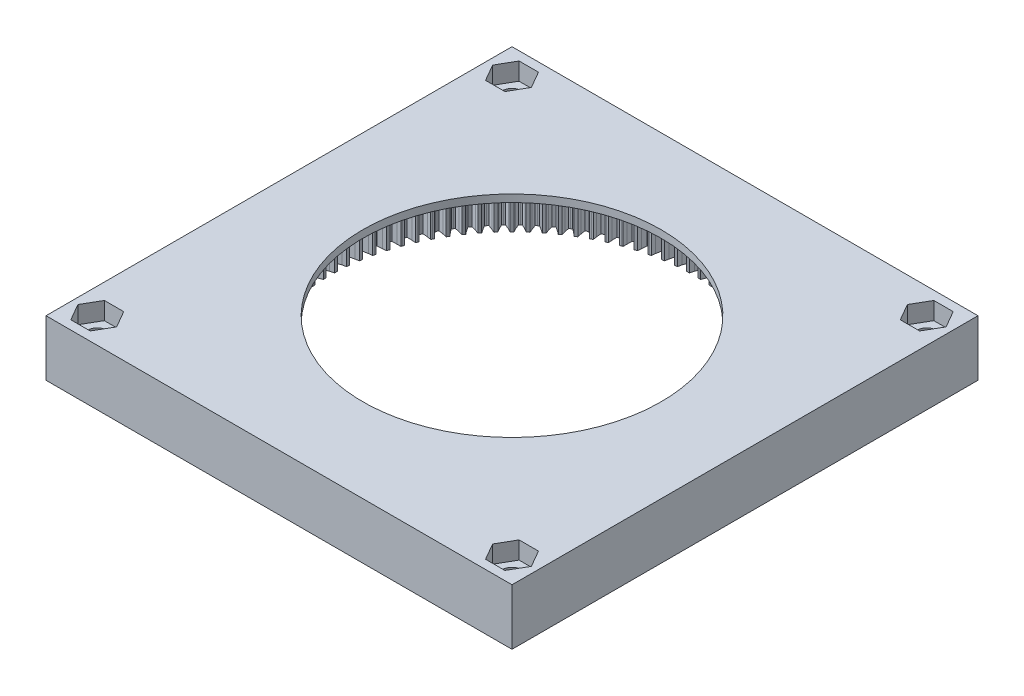
from build123d import *

# Parameters (mm, degrees)
SKETCH1_W           = 158.75
SKETCH1_H           = 158.75
BOSS_EXTRUDE1_DEPTH = 19.05
SKETCH7_R           = 3.37312
CUT_EXTRUDE2_DEPTH  = 19.05
SKETCH8_R           = 50.8
CUT_EXTRUDE3_DEPTH  = 19.05
CUT_EXTRUDE5_DEPTH  = 16.51
CUT_EXTRUDE6_DEPTH  = 5.969


with BuildPart() as part:
    # Sketch1 → Boss-Extrude1 (new body)
    with BuildSketch(Plane(origin=(0, 0, 0), x_dir=(1, 0, 0), z_dir=(0, 1, 0))):
        Rectangle(SKETCH1_W, SKETCH1_H)
    extrude(amount=BOSS_EXTRUDE1_DEPTH)

    # Sketch7 → Cut-Extrude2 (cut)
    with BuildSketch(Plane(origin=(0, 0, 0), x_dir=(1, 0, 0), z_dir=(0, 1, 0))):
        with Locations((-70.64375, 70.64375)):
            Circle(SKETCH7_R)
        with Locations((70.64375, 70.64375)):
            Circle(SKETCH7_R)
        with Locations((70.64375, -70.64375)):
            Circle(SKETCH7_R)
        with Locations((-70.64375, -70.64375)):
            Circle(SKETCH7_R)
    extrude(amount=CUT_EXTRUDE2_DEPTH, mode=Mode.SUBTRACT)

    # Sketch8 → Cut-Extrude3 (cut)
    with BuildSketch(Plane(origin=(0, 0, 0), x_dir=(1, 0, 0), z_dir=(0, 1, 0))):
        Circle(SKETCH8_R)
    extrude(amount=CUT_EXTRUDE3_DEPTH, mode=Mode.SUBTRACT)

    # Sketch10 → Cut-Extrude5 (cut)
    with BuildSketch(Plane.XZ):
        Polygon((61.894879047, -1.477025374), (63.199005913, -1.096565737), (64.767971828, -0.512567385), (64.77, 0), (64.767971828, 0.512567385), (63.199005913, 1.096565737), (61.894879047, 1.477025374), (61.881949919, 1.944718621), (61.865486833, 2.41230081), (63.143151044, 2.8738965), (64.672351403, 3.555258649), (64.6421912, 4.06694195), (64.607982658, 4.578370551), (63.005443179, 5.06270033), (61.680000452, 5.360522414), (61.637730133, 5.826480948), (61.591939805, 6.292106744), (62.838099005, 6.83301678), (64.321498752, 7.609053702), (64.259269204, 8.117833538), (64.193015297, 8.626104979), (62.563226745, 9.008854758), (61.221699073, 9.22286392), (61.150254387, 9.685248817), (61.07531753, 10.147080608), (62.285053697, 10.765170265), (63.716798532, 11.632819296), (63.62274523, 12.136687746), (63.524707431, 12.639796112), (61.874101838, 12.919455352), (60.521783617, 13.048806996), (60.421446524, 13.505793433), (60.317658879, 13.96200858), (61.486197737, 14.654838541), (62.860637218, 15.610675467), (62.735131346, 16.107643992), (62.605696568, 16.603603744), (60.940788118, 16.779068758), (59.583016332, 16.823252392), (59.454182814, 17.273036853), (59.321953985, 17.721834884), (60.444683845, 18.486670865), (61.756393687, 19.526923434), (61.59993056, 20.015030726), (61.439609621, 20.501884538), (59.766968949, 20.572462845), (58.409102102, 20.531304097), (58.252280608, 20.972111487), (58.09213244, 21.411721201), (59.164622401, 22.245544744), (60.408425884, 23.366107555), (60.221622991, 23.843427277), (60.031048605, 24.31925376), (58.357276858, 24.28466682), (57.00467383, 24.158328125), (56.820483263, 24.588418779), (56.633047789, 25.017105237), (57.651065222, 25.916625621), (58.822053621, 27.113076324), (58.605648188, 27.577724715), (58.385572465, 28.040645997), (56.717275256, 27.901030309), (55.375274154, 27.690010268), (55.164441429, 28.107686815), (54.95045837, 28.523758187), (55.909985627, 29.485425417), (57.003537587, 30.753042168), (56.758383666, 31.203185472), (56.509675144, 31.651374616), (54.853436481, 31.407281179), (53.527333569, 31.112412591), (53.290690747, 31.516026653), (53.051004598, 31.917840896), (53.948254861, 32.93785971), (54.960054632, 34.271639805), (54.687119735, 34.705501511), (54.410759953, 35.137189719), (52.773116252, 34.789581859), (51.468145053, 34.412028436), (51.206626055, 34.799987131), (50.942182746, 35.185958468), (51.77361498, 36.260303318), (52.69966945, 37.654982936), (52.400030726, 38.070850791), (52.09711035, 38.484334387), (50.484524643, 38.034583952), (49.205835282, 37.575835725), (48.920472204, 37.946607959), (48.632315373, 38.315213137), (49.394648294, 39.439644075), (50.231302749, 40.889719052), (49.906142735, 41.285951816), (49.577857253, 41.679598969), (47.996693679, 41.12948092), (46.749332559, 40.591348358), (46.441251598, 40.943470862), (46.130518469, 41.293255164), (46.820743497, 42.463334575), (47.564696044, 43.963082128), (47.215297998, 44.338116051), (46.862943004, 44.710373215), (45.319441693, 44.062058616), (44.108331578, 43.446665483), (43.77874859, 43.77874859), (43.446665483, 44.108331578), (44.062058616, 45.319441693), (44.710373215, 46.862943004), (44.338116051, 47.215297998), (43.963082128, 47.564696044), (42.463334575, 46.820743497), (41.293255164, 46.130518469), (40.943470862, 46.441251598), (40.591348358, 46.749332559), (41.12948092, 47.996693679), (41.679598969, 49.577857253), (41.285951816, 49.906142735), (40.889719052, 50.231302749), (39.439644075, 49.394648294), (38.315213137, 48.632315373), (37.946607959, 48.920472204), (37.575835725, 49.205835282), (38.034583952, 50.484524643), (38.484334387, 52.09711035), (38.070850791, 52.400030726), (37.654982936, 52.69966945), (36.260303318, 51.77361498), (35.185958468, 50.942182746), (34.799987131, 51.206626055), (34.412028436, 51.468145053), (34.789581859, 52.773116252), (35.137189719, 54.410759953), (34.705501511, 54.687119735), (34.271639805, 54.960054632), (32.93785971, 53.948254861), (31.917840896, 53.051004598), (31.516026653, 53.290690747), (31.112412591, 53.527333569), (31.407281179, 54.853436481), (31.651374616, 56.509675144), (31.203185472, 56.758383666), (30.753042168, 57.003537587), (29.485425417, 55.909985627), (28.523758187, 54.95045837), (28.107686815, 55.164441429), (27.690010268, 55.375274154), (27.901030309, 56.717275256), (28.040645997, 58.385572465), (27.577724715, 58.605648188), (27.113076324, 58.822053621), (25.916625621, 57.651065222), (25.017105237, 56.633047789), (24.588418779, 56.820483263), (24.158328125, 57.00467383), (24.28466682, 58.357276858), (24.31925376, 60.031048605), (23.843427277, 60.221622991), (23.366107555, 60.408425884), (22.245544744, 59.164622401), (21.411721201, 58.09213244), (20.972111487, 58.252280608), (20.531304097, 58.409102102), (20.572462845, 59.766968949), (20.501884538, 61.439609621), (20.015030726, 61.59993056), (19.526923434, 61.756393687), (18.486670865, 60.444683845), (17.721834884, 59.321953985), (17.273036853, 59.454182814), (16.823252392, 59.583016332), (16.779068758, 60.940788118), (16.603603744, 62.605696568), (16.107643992, 62.735131346), (15.610675467, 62.860637218), (14.654838541, 61.486197737), (13.96200858, 60.317658879), (13.505793433, 60.421446524), (13.048806996, 60.521783617), (12.919455352, 61.874101838), (12.639796112, 63.524707431), (12.136687746, 63.62274523), (11.632819296, 63.716798532), (10.765170265, 62.285053697), (10.147080608, 61.07531753), (9.685248817, 61.150254387), (9.22286392, 61.221699073), (9.008854758, 62.563226745), (8.626104979, 64.193015297), (8.117833538, 64.259269204), (7.609053702, 64.321498752), (6.83301678, 62.838099005), (6.292106744, 61.591939805), (5.826480948, 61.637730133), (5.360522414, 61.680000452), (5.06270033, 63.005443179), (4.578370551, 64.607982658), (4.06694195, 64.6421912), (3.555258649, 64.672351403), (2.8738965, 63.143151044), (2.41230081, 61.865486833), (1.944718621, 61.881949919), (1.477025374, 61.894879047), (1.096565737, 63.199005913), (0.512567385, 64.767971828), (0, 64.77), (-0.512567385, 64.767971828), (-1.096565737, 63.199005913), (-1.477025374, 61.894879047), (-1.944718621, 61.881949919), (-2.41230081, 61.865486833), (-2.8738965, 63.143151044), (-3.555258649, 64.672351403), (-4.06694195, 64.6421912), (-4.578370551, 64.607982658), (-5.06270033, 63.005443179), (-5.360522414, 61.680000452), (-5.826480948, 61.637730133), (-6.292106744, 61.591939805), (-6.83301678, 62.838099005), (-7.609053702, 64.321498752), (-8.117833538, 64.259269204), (-8.626104979, 64.193015297), (-9.008854758, 62.563226745), (-9.22286392, 61.221699073), (-9.685248817, 61.150254387), (-10.147080608, 61.07531753), (-10.765170265, 62.285053697), (-11.632819296, 63.716798532), (-12.136687746, 63.62274523), (-12.639796112, 63.524707431), (-12.919455352, 61.874101838), (-13.048806996, 60.521783617), (-13.505793433, 60.421446524), (-13.96200858, 60.317658879), (-14.654838541, 61.486197737), (-15.610675467, 62.860637218), (-16.107643992, 62.735131346), (-16.603603744, 62.605696568), (-16.779068758, 60.940788118), (-16.823252392, 59.583016332), (-17.273036853, 59.454182814), (-17.721834884, 59.321953985), (-18.486670865, 60.444683845), (-19.526923434, 61.756393687), (-20.015030726, 61.59993056), (-20.501884538, 61.439609621), (-20.572462845, 59.766968949), (-20.531304097, 58.409102102), (-20.972111487, 58.252280608), (-21.411721201, 58.09213244), (-22.245544744, 59.164622401), (-23.366107555, 60.408425884), (-23.843427277, 60.221622991), (-24.31925376, 60.031048605), (-24.28466682, 58.357276858), (-24.158328125, 57.00467383), (-24.588418779, 56.820483263), (-25.017105237, 56.633047789), (-25.916625621, 57.651065222), (-27.113076324, 58.822053621), (-27.577724715, 58.605648188), (-28.040645997, 58.385572465), (-27.901030309, 56.717275256), (-27.690010268, 55.375274154), (-28.107686815, 55.164441429), (-28.523758187, 54.95045837), (-29.485425417, 55.909985627), (-30.753042168, 57.003537587), (-31.203185472, 56.758383666), (-31.651374616, 56.509675144), (-31.407281179, 54.853436481), (-31.112412591, 53.527333569), (-31.516026653, 53.290690747), (-31.917840896, 53.051004598), (-32.93785971, 53.948254861), (-34.271639805, 54.960054632), (-34.705501511, 54.687119735), (-35.137189719, 54.410759953), (-34.789581859, 52.773116252), (-34.412028436, 51.468145053), (-34.799987131, 51.206626055), (-35.185958468, 50.942182746), (-36.260303318, 51.77361498), (-37.654982936, 52.69966945), (-38.070850791, 52.400030726), (-38.484334387, 52.09711035), (-38.034583952, 50.484524643), (-37.575835725, 49.205835282), (-37.946607959, 48.920472204), (-38.315213137, 48.632315373), (-39.439644075, 49.394648294), (-40.889719052, 50.231302749), (-41.285951816, 49.906142735), (-41.679598969, 49.577857253), (-41.12948092, 47.996693679), (-40.591348358, 46.749332559), (-40.943470862, 46.441251598), (-41.293255164, 46.130518469), (-42.463334575, 46.820743497), (-43.963082128, 47.564696044), (-44.338116051, 47.215297998), (-44.710373215, 46.862943004), (-44.062058616, 45.319441693), (-43.446665483, 44.108331578), (-43.77874859, 43.77874859), (-44.108331578, 43.446665483), (-45.319441693, 44.062058616), (-46.862943004, 44.710373215), (-47.215297998, 44.338116051), (-47.564696044, 43.963082128), (-46.820743497, 42.463334575), (-46.130518469, 41.293255164), (-46.441251598, 40.943470862), (-46.749332559, 40.591348358), (-47.996693679, 41.12948092), (-49.577857253, 41.679598969), (-49.906142735, 41.285951816), (-50.231302749, 40.889719052), (-49.394648294, 39.439644075), (-48.632315373, 38.315213137), (-48.920472204, 37.946607959), (-49.205835282, 37.575835725), (-50.484524643, 38.034583952), (-52.09711035, 38.484334387), (-52.400030726, 38.070850791), (-52.69966945, 37.654982936), (-51.77361498, 36.260303318), (-50.942182746, 35.185958468), (-51.206626055, 34.799987131), (-51.468145053, 34.412028436), (-52.773116252, 34.789581859), (-54.410759953, 35.137189719), (-54.687119735, 34.705501511), (-54.960054632, 34.271639805), (-53.948254861, 32.93785971), (-53.051004598, 31.917840896), (-53.290690747, 31.516026653), (-53.527333569, 31.112412591), (-54.853436481, 31.407281179), (-56.509675144, 31.651374616), (-56.758383666, 31.203185472), (-57.003537587, 30.753042168), (-55.909985627, 29.485425417), (-54.95045837, 28.523758187), (-55.164441429, 28.107686815), (-55.375274154, 27.690010268), (-56.717275256, 27.901030309), (-58.385572465, 28.040645997), (-58.605648188, 27.577724715), (-58.822053621, 27.113076324), (-57.651065222, 25.916625621), (-56.633047789, 25.017105237), (-56.820483263, 24.588418779), (-57.00467383, 24.158328125), (-58.357276858, 24.28466682), (-60.031048605, 24.31925376), (-60.221622991, 23.843427277), (-60.408425884, 23.366107555), (-59.164622401, 22.245544744), (-58.09213244, 21.411721201), (-58.252280608, 20.972111487), (-58.409102102, 20.531304097), (-59.766968949, 20.572462845), (-61.439609621, 20.501884538), (-61.59993056, 20.015030726), (-61.756393687, 19.526923434), (-60.444683845, 18.486670865), (-59.321953985, 17.721834884), (-59.454182814, 17.273036853), (-59.583016332, 16.823252392), (-60.940788118, 16.779068758), (-62.605696568, 16.603603744), (-62.735131346, 16.107643992), (-62.860637218, 15.610675467), (-61.486197737, 14.654838541), (-60.317658879, 13.96200858), (-60.421446524, 13.505793433), (-60.521783617, 13.048806996), (-61.874101838, 12.919455352), (-63.524707431, 12.639796112), (-63.62274523, 12.136687746), (-63.716798532, 11.632819296), (-62.285053697, 10.765170265), (-61.07531753, 10.147080608), (-61.150254387, 9.685248817), (-61.221699073, 9.22286392), (-62.563226745, 9.008854758), (-64.193015297, 8.626104979), (-64.259269204, 8.117833538), (-64.321498752, 7.609053702), (-62.838099005, 6.83301678), (-61.591939805, 6.292106744), (-61.637730133, 5.826480948), (-61.680000452, 5.360522414), (-63.005443179, 5.06270033), (-64.607982658, 4.578370551), (-64.6421912, 4.06694195), (-64.672351403, 3.555258649), (-63.143151044, 2.8738965), (-61.865486833, 2.41230081), (-61.881949919, 1.944718621), (-61.894879047, 1.477025374), (-63.199005913, 1.096565737), (-64.767971828, 0.512567385), (-64.77, 0), (-64.767971828, -0.512567385), (-63.199005913, -1.096565737), (-61.894879047, -1.477025374), (-61.881949919, -1.944718621), (-61.865486833, -2.41230081), (-63.143151044, -2.8738965), (-64.672351403, -3.555258649), (-64.6421912, -4.06694195), (-64.607982658, -4.578370551), (-63.005443179, -5.06270033), (-61.680000452, -5.360522414), (-61.637730133, -5.826480948), (-61.591939805, -6.292106744), (-62.838099005, -6.83301678), (-64.321498752, -7.609053702), (-64.259269204, -8.117833538), (-64.193015297, -8.626104979), (-62.563226745, -9.008854758), (-61.221699073, -9.22286392), (-61.150254387, -9.685248817), (-61.07531753, -10.147080608), (-62.285053697, -10.765170265), (-63.716798532, -11.632819296), (-63.62274523, -12.136687746), (-63.524707431, -12.639796112), (-61.874101838, -12.919455352), (-60.521783617, -13.048806996), (-60.421446524, -13.505793433), (-60.317658879, -13.96200858), (-61.486197737, -14.654838541), (-62.860637218, -15.610675467), (-62.735131346, -16.107643992), (-62.605696568, -16.603603744), (-60.940788118, -16.779068758), (-59.583016332, -16.823252392), (-59.454182814, -17.273036853), (-59.321953985, -17.721834884), (-60.444683845, -18.486670865), (-61.756393687, -19.526923434), (-61.59993056, -20.015030726), (-61.439609621, -20.501884538), (-59.766968949, -20.572462845), (-58.409102102, -20.531304097), (-58.252280608, -20.972111487), (-58.09213244, -21.411721201), (-59.164622401, -22.245544744), (-60.408425884, -23.366107555), (-60.221622991, -23.843427277), (-60.031048605, -24.31925376), (-58.357276858, -24.28466682), (-57.00467383, -24.158328125), (-56.820483263, -24.588418779), (-56.633047789, -25.017105237), (-57.651065222, -25.916625621), (-58.822053621, -27.113076324), (-58.605648188, -27.577724715), (-58.385572465, -28.040645997), (-56.717275256, -27.901030309), (-55.375274154, -27.690010268), (-55.164441429, -28.107686815), (-54.95045837, -28.523758187), (-55.909985627, -29.485425417), (-57.003537587, -30.753042168), (-56.758383666, -31.203185472), (-56.509675144, -31.651374616), (-54.853436481, -31.407281179), (-53.527333569, -31.112412591), (-53.290690747, -31.516026653), (-53.051004598, -31.917840896), (-53.948254861, -32.93785971), (-54.960054632, -34.271639805), (-54.687119735, -34.705501511), (-54.410759953, -35.137189719), (-52.773116252, -34.789581859), (-51.468145053, -34.412028436), (-51.206626055, -34.799987131), (-50.942182746, -35.185958468), (-51.77361498, -36.260303318), (-52.69966945, -37.654982936), (-52.400030726, -38.070850791), (-52.09711035, -38.484334387), (-50.484524643, -38.034583952), (-49.205835282, -37.575835725), (-48.920472204, -37.946607959), (-48.632315373, -38.315213137), (-49.394648294, -39.439644075), (-50.231302749, -40.889719052), (-49.906142735, -41.285951816), (-49.577857253, -41.679598969), (-47.996693679, -41.12948092), (-46.749332559, -40.591348358), (-46.441251598, -40.943470862), (-46.130518469, -41.293255164), (-46.820743497, -42.463334575), (-47.564696044, -43.963082128), (-47.215297998, -44.338116051), (-46.862943004, -44.710373215), (-45.319441693, -44.062058616), (-44.108331578, -43.446665483), (-43.77874859, -43.77874859), (-43.446665483, -44.108331578), (-44.062058616, -45.319441693), (-44.710373215, -46.862943004), (-44.338116051, -47.215297998), (-43.963082128, -47.564696044), (-42.463334575, -46.820743497), (-41.293255164, -46.130518469), (-40.943470862, -46.441251598), (-40.591348358, -46.749332559), (-41.12948092, -47.996693679), (-41.679598969, -49.577857253), (-41.285951816, -49.906142735), (-40.889719052, -50.231302749), (-39.439644075, -49.394648294), (-38.315213137, -48.632315373), (-37.946607959, -48.920472204), (-37.575835725, -49.205835282), (-38.034583952, -50.484524643), (-38.484334387, -52.09711035), (-38.070850791, -52.400030726), (-37.654982936, -52.69966945), (-36.260303318, -51.77361498), (-35.185958468, -50.942182746), (-34.799987131, -51.206626055), (-34.412028436, -51.468145053), (-34.789581859, -52.773116252), (-35.137189719, -54.410759953), (-34.705501511, -54.687119735), (-34.271639805, -54.960054632), (-32.93785971, -53.948254861), (-31.917840896, -53.051004598), (-31.516026653, -53.290690747), (-31.112412591, -53.527333569), (-31.407281179, -54.853436481), (-31.651374616, -56.509675144), (-31.203185472, -56.758383666), (-30.753042168, -57.003537587), (-29.485425417, -55.909985627), (-28.523758187, -54.95045837), (-28.107686815, -55.164441429), (-27.690010268, -55.375274154), (-27.901030309, -56.717275256), (-28.040645997, -58.385572465), (-27.577724715, -58.605648188), (-27.113076324, -58.822053621), (-25.916625621, -57.651065222), (-25.017105237, -56.633047789), (-24.588418779, -56.820483263), (-24.158328125, -57.00467383), (-24.28466682, -58.357276858), (-24.31925376, -60.031048605), (-23.843427277, -60.221622991), (-23.366107555, -60.408425884), (-22.245544744, -59.164622401), (-21.411721201, -58.09213244), (-20.972111487, -58.252280608), (-20.531304097, -58.409102102), (-20.572462845, -59.766968949), (-20.501884538, -61.439609621), (-20.015030726, -61.59993056), (-19.526923434, -61.756393687), (-18.486670865, -60.444683845), (-17.721834884, -59.321953985), (-17.273036853, -59.454182814), (-16.823252392, -59.583016332), (-16.779068758, -60.940788118), (-16.603603744, -62.605696568), (-16.107643992, -62.735131346), (-15.610675467, -62.860637218), (-14.654838541, -61.486197737), (-13.96200858, -60.317658879), (-13.505793433, -60.421446524), (-13.048806996, -60.521783617), (-12.919455352, -61.874101838), (-12.639796112, -63.524707431), (-12.136687746, -63.62274523), (-11.632819296, -63.716798532), (-10.765170265, -62.285053697), (-10.147080608, -61.07531753), (-9.685248817, -61.150254387), (-9.22286392, -61.221699073), (-9.008854758, -62.563226745), (-8.626104979, -64.193015297), (-8.117833538, -64.259269204), (-7.609053702, -64.321498752), (-6.83301678, -62.838099005), (-6.292106744, -61.591939805), (-5.826480948, -61.637730133), (-5.360522414, -61.680000452), (-5.06270033, -63.005443179), (-4.578370551, -64.607982658), (-4.06694195, -64.6421912), (-3.555258649, -64.672351403), (-2.8738965, -63.143151044), (-2.41230081, -61.865486833), (-1.944718621, -61.881949919), (-1.477025374, -61.894879047), (-1.096565737, -63.199005913), (-0.512567385, -64.767971828), (0, -64.77), (0.512567385, -64.767971828), (1.096565737, -63.199005913), (1.477025374, -61.894879047), (1.944718621, -61.881949919), (2.41230081, -61.865486833), (2.8738965, -63.143151044), (3.555258649, -64.672351403), (4.06694195, -64.6421912), (4.578370551, -64.607982658), (5.06270033, -63.005443179), (5.360522414, -61.680000452), (5.826480948, -61.637730133), (6.292106744, -61.591939805), (6.83301678, -62.838099005), (7.609053702, -64.321498752), (8.117833538, -64.259269204), (8.626104979, -64.193015297), (9.008854758, -62.563226745), (9.22286392, -61.221699073), (9.685248817, -61.150254387), (10.147080608, -61.07531753), (10.765170265, -62.285053697), (11.632819296, -63.716798532), (12.136687746, -63.62274523), (12.639796112, -63.524707431), (12.919455352, -61.874101838), (13.048806996, -60.521783617), (13.505793433, -60.421446524), (13.96200858, -60.317658879), (14.654838541, -61.486197737), (15.610675467, -62.860637218), (16.107643992, -62.735131346), (16.603603744, -62.605696568), (16.779068758, -60.940788118), (16.823252392, -59.583016332), (17.273036853, -59.454182814), (17.721834884, -59.321953985), (18.486670865, -60.444683845), (19.526923434, -61.756393687), (20.015030726, -61.59993056), (20.501884538, -61.439609621), (20.572462845, -59.766968949), (20.531304097, -58.409102102), (20.972111487, -58.252280608), (21.411721201, -58.09213244), (22.245544744, -59.164622401), (23.366107555, -60.408425884), (23.843427277, -60.221622991), (24.31925376, -60.031048605), (24.28466682, -58.357276858), (24.158328125, -57.00467383), (24.588418779, -56.820483263), (25.017105237, -56.633047789), (25.916625621, -57.651065222), (27.113076324, -58.822053621), (27.577724715, -58.605648188), (28.040645997, -58.385572465), (27.901030309, -56.717275256), (27.690010268, -55.375274154), (28.107686815, -55.164441429), (28.523758187, -54.95045837), (29.485425417, -55.909985627), (30.753042168, -57.003537587), (31.203185472, -56.758383666), (31.651374616, -56.509675144), (31.407281179, -54.853436481), (31.112412591, -53.527333569), (31.516026653, -53.290690747), (31.917840896, -53.051004598), (32.93785971, -53.948254861), (34.271639805, -54.960054632), (34.705501511, -54.687119735), (35.137189719, -54.410759953), (34.789581859, -52.773116252), (34.412028436, -51.468145053), (34.799987131, -51.206626055), (35.185958468, -50.942182746), (36.260303318, -51.77361498), (37.654982936, -52.69966945), (38.070850791, -52.400030726), (38.484334387, -52.09711035), (38.034583952, -50.484524643), (37.575835725, -49.205835282), (37.946607959, -48.920472204), (38.315213137, -48.632315373), (39.439644075, -49.394648294), (40.889719052, -50.231302749), (41.285951816, -49.906142735), (41.679598969, -49.577857253), (41.12948092, -47.996693679), (40.591348358, -46.749332559), (40.943470862, -46.441251598), (41.293255164, -46.130518469), (42.463334575, -46.820743497), (43.963082128, -47.564696044), (44.338116051, -47.215297998), (44.710373215, -46.862943004), (44.062058616, -45.319441693), (43.446665483, -44.108331578), (43.77874859, -43.77874859), (44.108331578, -43.446665483), (45.319441693, -44.062058616), (46.862943004, -44.710373215), (47.215297998, -44.338116051), (47.564696044, -43.963082128), (46.820743497, -42.463334575), (46.130518469, -41.293255164), (46.441251598, -40.943470862), (46.749332559, -40.591348358), (47.996693679, -41.12948092), (49.577857253, -41.679598969), (49.906142735, -41.285951816), (50.231302749, -40.889719052), (49.394648294, -39.439644075), (48.632315373, -38.315213137), (48.920472204, -37.946607959), (49.205835282, -37.575835725), (50.484524643, -38.034583952), (52.09711035, -38.484334387), (52.400030726, -38.070850791), (52.69966945, -37.654982936), (51.77361498, -36.260303318), (50.942182746, -35.185958468), (51.206626055, -34.799987131), (51.468145053, -34.412028436), (52.773116252, -34.789581859), (54.410759953, -35.137189719), (54.687119735, -34.705501511), (54.960054632, -34.271639805), (53.948254861, -32.93785971), (53.051004598, -31.917840896), (53.290690747, -31.516026653), (53.527333569, -31.112412591), (54.853436481, -31.407281179), (56.509675144, -31.651374616), (56.758383666, -31.203185472), (57.003537587, -30.753042168), (55.909985627, -29.485425417), (54.95045837, -28.523758187), (55.164441429, -28.107686815), (55.375274154, -27.690010268), (56.717275256, -27.901030309), (58.385572465, -28.040645997), (58.605648188, -27.577724715), (58.822053621, -27.113076324), (57.651065222, -25.916625621), (56.633047789, -25.017105237), (56.820483263, -24.588418779), (57.00467383, -24.158328125), (58.357276858, -24.28466682), (60.031048605, -24.31925376), (60.221622991, -23.843427277), (60.408425884, -23.366107555), (59.164622401, -22.245544744), (58.09213244, -21.411721201), (58.252280608, -20.972111487), (58.409102102, -20.531304097), (59.766968949, -20.572462845), (61.439609621, -20.501884538), (61.59993056, -20.015030726), (61.756393687, -19.526923434), (60.444683845, -18.486670865), (59.321953985, -17.721834884), (59.454182814, -17.273036853), (59.583016332, -16.823252392), (60.940788118, -16.779068758), (62.605696568, -16.603603744), (62.735131346, -16.107643992), (62.860637218, -15.610675467), (61.486197737, -14.654838541), (60.317658879, -13.96200858), (60.421446524, -13.505793433), (60.521783617, -13.048806996), (61.874101838, -12.919455352), (63.524707431, -12.639796112), (63.62274523, -12.136687746), (63.716798532, -11.632819296), (62.285053697, -10.765170265), (61.07531753, -10.147080608), (61.150254387, -9.685248817), (61.221699073, -9.22286392), (62.563226745, -9.008854758), (64.193015297, -8.626104979), (64.259269204, -8.117833538), (64.321498752, -7.609053702), (62.838099005, -6.83301678), (61.591939805, -6.292106744), (61.637730133, -5.826480948), (61.680000452, -5.360522414), (63.005443179, -5.06270033), (64.607982658, -4.578370551), (64.6421912, -4.06694195), (64.672351403, -3.555258649), (63.143151044, -2.8738965), (61.865486833, -2.41230081), (61.881949919, -1.944718621), align=None)
    extrude(amount=-CUT_EXTRUDE5_DEPTH, mode=Mode.SUBTRACT)

    # Sketch11 → Cut-Extrude6 (cut)
    with BuildSketch(Plane(origin=(0, 19.05, 0), x_dir=(1, 0, 0), z_dir=(0, 1, 0))):
        Polygon((-77.242863577, 70.64375), (-73.943306788, 64.92875), (-67.344193212, 64.92875), (-64.044636423, 70.64375), (-67.344193212, 76.35875), (-73.943306788, 76.35875), align=None)
        Polygon((64.044636423, 70.64375), (67.344193212, 64.92875), (73.943306788, 64.92875), (77.242863577, 70.64375), (73.943306788, 76.35875), (67.344193212, 76.35875), align=None)
        Polygon((64.044636423, -70.64375), (67.344193212, -76.35875), (73.943306788, -76.35875), (77.242863577, -70.64375), (73.943306788, -64.92875), (67.344193212, -64.92875), align=None)
        Polygon((-77.242863577, -70.64375), (-73.943306788, -76.35875), (-67.344193212, -76.35875), (-64.044636423, -70.64375), (-67.344193212, -64.92875), (-73.943306788, -64.92875), align=None)
    extrude(amount=-CUT_EXTRUDE6_DEPTH, mode=Mode.SUBTRACT)


solid = part.part
